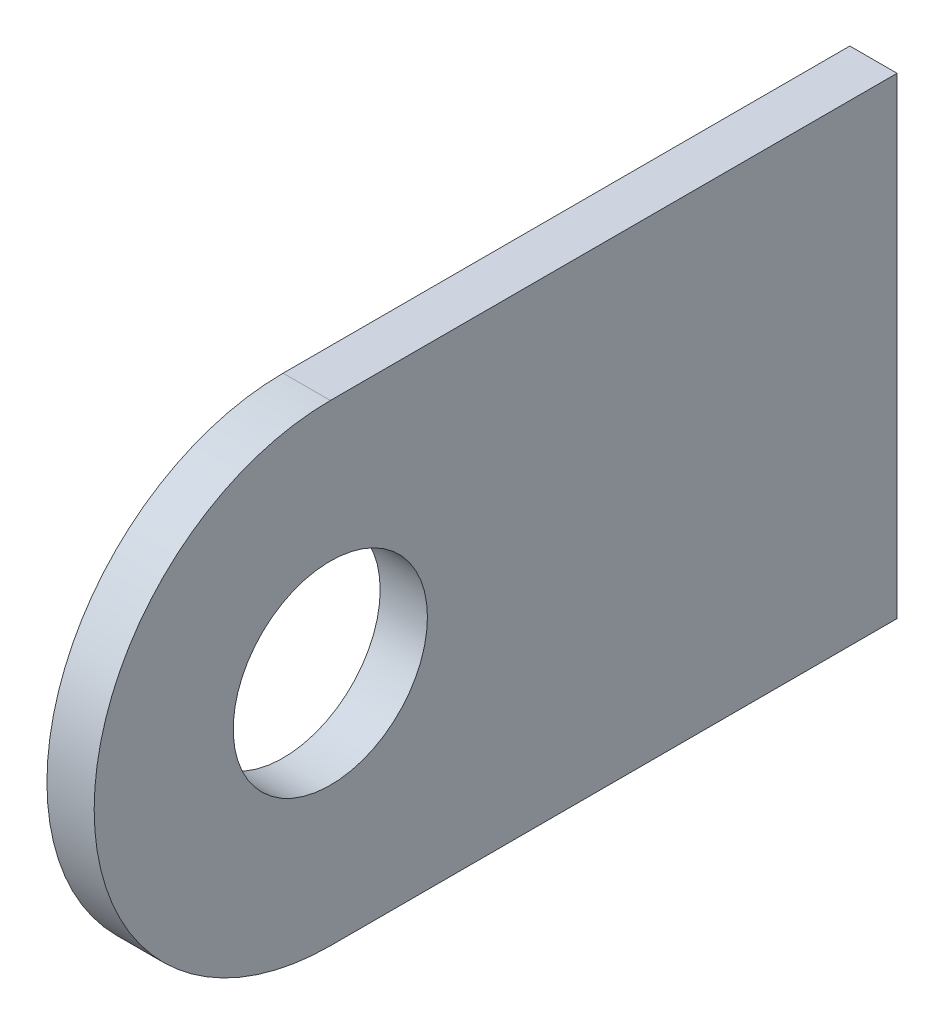
from build123d import *

# Parameters (mm, degrees)
BOSS_EXTRUDE1_DEPTH     = 1.5875
F_1_4_CLEARANCE_HOLE1_D = 6.5278


with BuildPart() as part:
    # Sketch1 → Boss-Extrude1 (new body)
    with BuildSketch(Plane(origin=(0, 0, 0), x_dir=(0, 0, -1), z_dir=(1, 0, 0))):
        with BuildLine():
            Line((3.175, -7.9375), (3.175, 7.9375))
            Line((3.175, 7.9375), (-15.875, 7.9375))
            ThreePointArc((-15.875, 7.9375), (-23.8125, 0), (-15.875, -7.9375))
            Line((-15.875, -7.9375), (3.175, -7.9375))
        make_face()
    extrude(amount=BOSS_EXTRUDE1_DEPTH)

    # 1/4 Clearance Hole1 (through all)
    with Locations(Plane(origin=(1.5875, 0, 0), x_dir=(0, 0, -1), z_dir=(1, 0, 0))):
        with Locations((-15.875, 0)):
            Hole(F_1_4_CLEARANCE_HOLE1_D / 2)


solid = part.part
